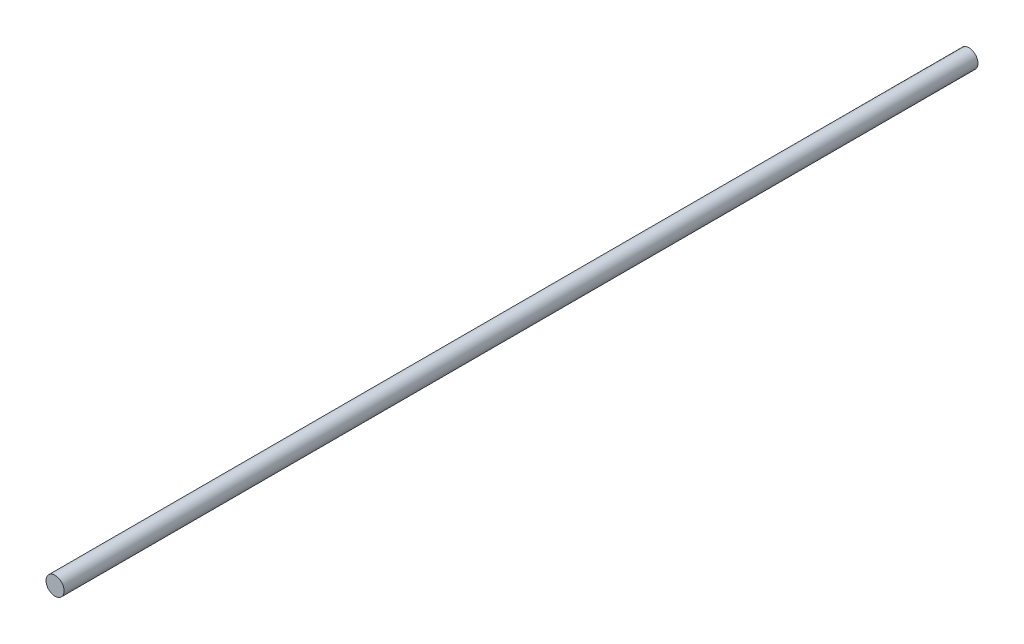
from build123d import *

# Parameters (mm, degrees)
SKETCH1_R                = 4
BOSS_EXTRUDE1_DEPTH      = 330
BOSS_EXTRUDE1_DEPTH_BACK = 73


with BuildPart() as part:
    # Sketch1 → Boss-Extrude1 (new body, two sides)
    with BuildSketch(Plane.XY) as boss_extrude1_sk:
        Circle(SKETCH1_R)
    extrude(amount=BOSS_EXTRUDE1_DEPTH)
    extrude(boss_extrude1_sk.sketch, amount=-BOSS_EXTRUDE1_DEPTH_BACK)


solid = part.part
